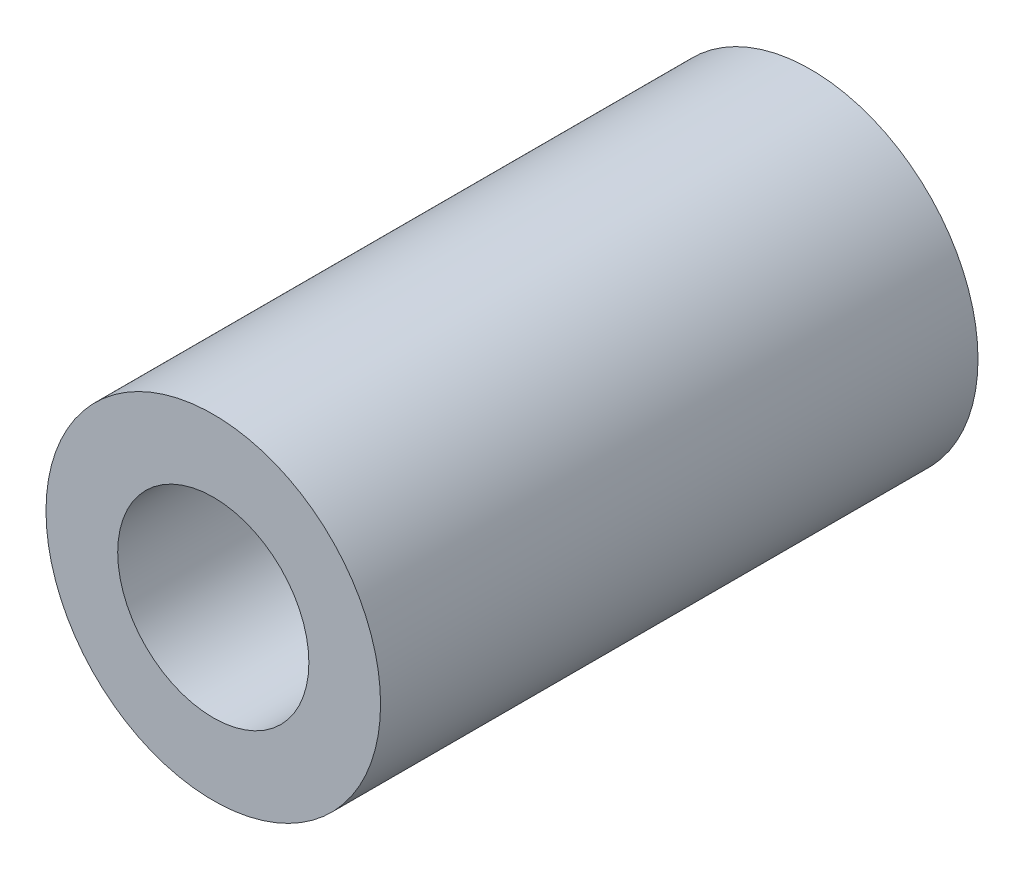
from build123d import *

# Parameters (mm, degrees)
SKETCH1_R           = 7
SKETCH1_R_2         = 3
BOSS_EXTRUDE1_DEPTH = 25
SKETCH3_R           = 4
CUT_EXTRUDE1_DEPTH  = 13


with BuildPart() as part:
    # Sketch1 → Boss-Extrude1 (new body)
    with BuildSketch(Plane(origin=(0, 0, 0), x_dir=(0, 1, 0), z_dir=(0, 0, 1))):
        Circle(SKETCH1_R)
        Circle(SKETCH1_R_2, mode=Mode.SUBTRACT)
    extrude(amount=BOSS_EXTRUDE1_DEPTH)

    # Sketch3 → Cut-Extrude1 (cut)
    with BuildSketch(Plane.XY.offset(25)):
        Circle(SKETCH3_R)
    extrude(amount=-CUT_EXTRUDE1_DEPTH, mode=Mode.SUBTRACT)


solid = part.part
